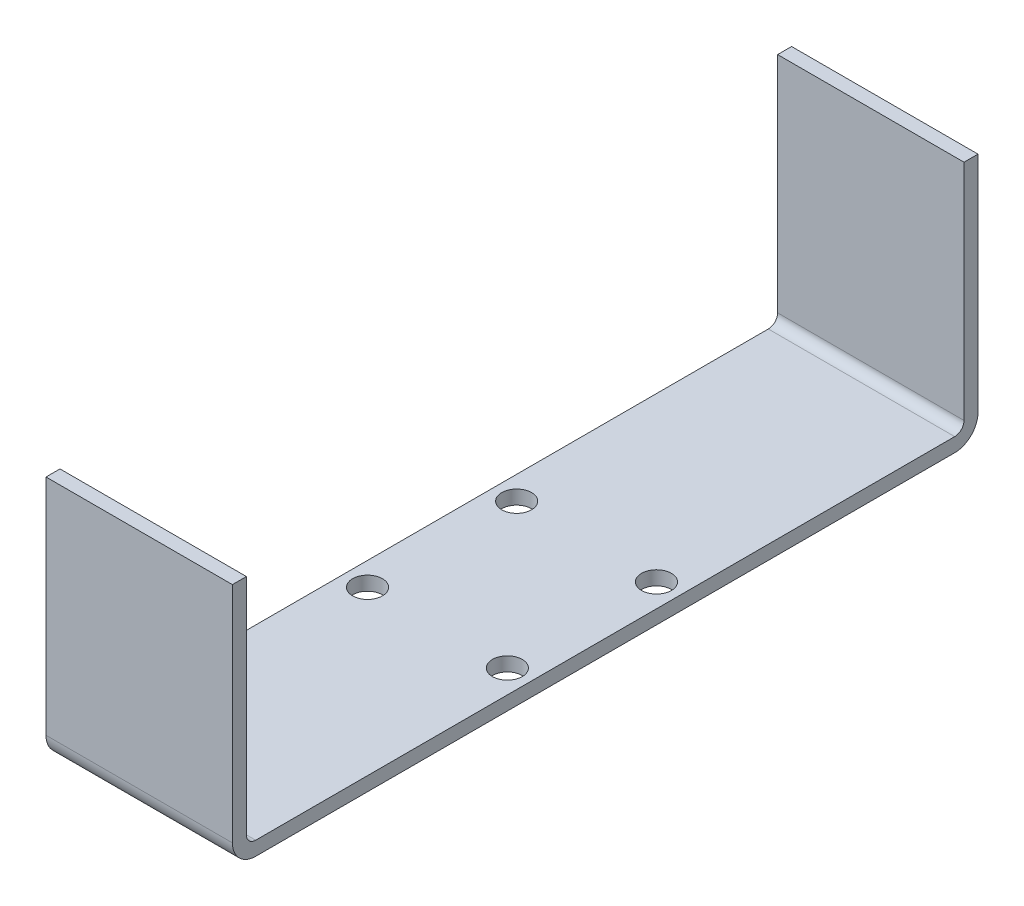
from build123d import *

# Parameters (mm, degrees)
SKETCH2_W           = 20
SKETCH2_H           = 80
SKETCH2_R           = 1.6
BOSS_EXTRUDE1_DEPTH = 1.5
SKETCH3_W           = 20
SKETCH3_H           = 1.5
BOSS_EXTRUDE2_DEPTH = 25
FILLET1_R           = 1
FILLET2_R           = 2.5


with BuildPart() as part:
    # Sketch2 → Boss-Extrude1 (new body)
    with BuildSketch(Plane(origin=(0, 0, 0), x_dir=(1, 0, 0), z_dir=(0, 1, 0))):
        Rectangle(SKETCH2_W, SKETCH2_H)
        with Locations((-7.5, 8)):
            Circle(SKETCH2_R, mode=Mode.SUBTRACT)
        with Locations((7.5, 8)):
            Circle(SKETCH2_R, mode=Mode.SUBTRACT)
        with Locations((-7.5, -8)):
            Circle(SKETCH2_R, mode=Mode.SUBTRACT)
        with Locations((7.5, -8)):
            Circle(SKETCH2_R, mode=Mode.SUBTRACT)
    extrude(amount=BOSS_EXTRUDE1_DEPTH)

    # Sketch3 → Boss-Extrude2 (add)
    with BuildSketch(Plane(origin=(0, 1.5, 0), x_dir=(1, 0, 0), z_dir=(0, 1, 0))):
        with Locations((0, 39.25)):
            Rectangle(SKETCH3_W, SKETCH3_H)
        with Locations((0, -39.25)):
            Rectangle(SKETCH3_W, SKETCH3_H)
    extrude(amount=BOSS_EXTRUDE2_DEPTH)

    # Fillet1
    fillet1_edges = [part.edges().sort_by_distance(p)[0] for p in [
        (0, 1.5, -38.5),
        (0, 1.5, 38.5),
    ]]
    fillet(fillet1_edges, radius=FILLET1_R)

    # Fillet2
    fillet2_edges = [part.edges().sort_by_distance(p)[0] for p in [
        (0, 0, 40),
        (0, 0, -40),
    ]]
    fillet(fillet2_edges, radius=FILLET2_R)


solid = part.part
